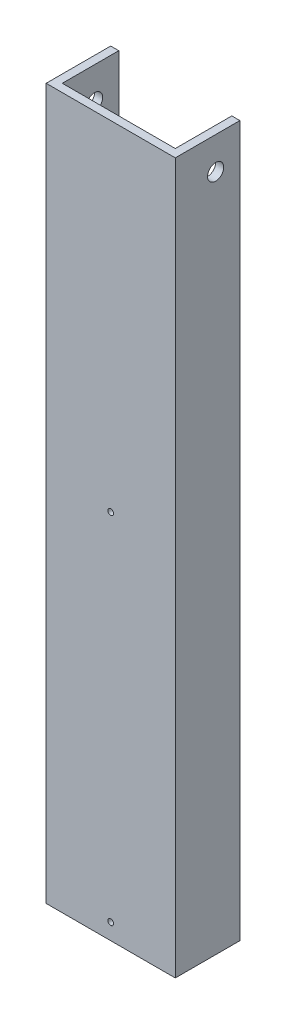
from build123d import *

# Parameters (mm, degrees)
BOSS_EXTRUDE1_DEPTH       = 279.4
SKETCH2_R                 = 3.175
CUT_EXTRUDE1_DEPTH        = 51.8
F_4_40_TAPPED_HOLE1_D     = 2.2606
F_4_40_TAPPED_HOLE1_DEPTH = 3.175


with BuildPart() as part:
    # Sketch1 → Boss-Extrude1 (new body)
    with BuildSketch(Plane(origin=(0, 0, 0), x_dir=(1, 0, 0), z_dir=(0, 1, 0))):
        Polygon((-25.4, 25.4), (-25.4, 0), (25.4, 0), (25.4, 25.4), (22.225, 25.4), (22.225, 3.175), (-22.225, 3.175), (-22.225, 25.4), align=None)
    extrude(amount=BOSS_EXTRUDE1_DEPTH)

    # Sketch2 → Cut-Extrude1 (cut, through all)
    with BuildSketch(Plane(origin=(25.4, 0, 0), x_dir=(0, 0, -1), z_dir=(1, 0, 0))):
        with Locations((15.875, 266.7)):
            Circle(SKETCH2_R)
    extrude(amount=-CUT_EXTRUDE1_DEPTH, mode=Mode.SUBTRACT)

    # #4-40 Tapped Hole1
    with Locations(Plane.XY):
        with Locations((0, 146.05), (0, 6.35)):
            Hole(F_4_40_TAPPED_HOLE1_D / 2, depth=F_4_40_TAPPED_HOLE1_DEPTH)


solid = part.part
